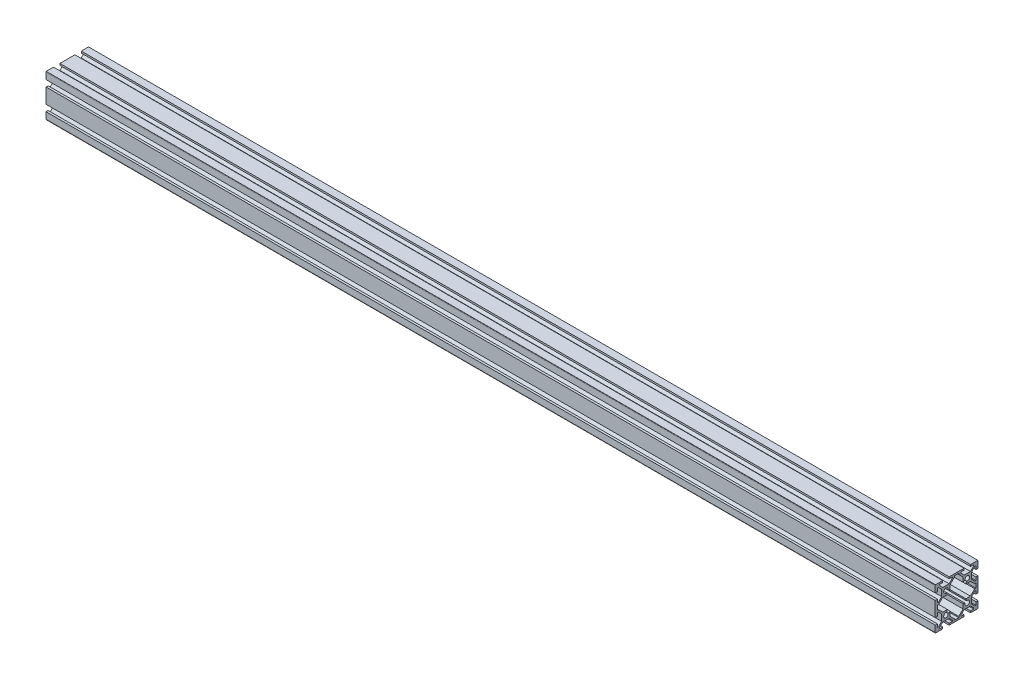
from build123d import *

# Parameters (mm, degrees)
BOSS_EXTRUDE1_DEPTH = 832


with BuildPart() as part:
    # Sketch1 → Boss-Extrude1 (new body)
    with BuildSketch(Plane(origin=(0, 0, 0), x_dir=(0, 0, -1), z_dir=(1, 0, 0))):
        with BuildLine():
            Line((-20, 19), (-20, 13))
            Line((-20, 13), (-18, 13))
            Line((-18, 13), (-18, 16))
            Line((-18, 16), (-17.060660172, 16))
            Line((-17.060660172, 16), (-14, 12.939339828))
            Line((-14, 12.939339828), (-14, 7.060660172))
            Line((-14, 7.060660172), (-17.060660172, 4))
            Line((-17.060660172, 4), (-18, 4))
            Line((-18, 4), (-18, 7))
            Line((-18, 7), (-20, 7))
            Line((-20, 7), (-20, -7))
            Line((-20, -7), (-18, -7))
            Line((-18, -7), (-18, -4))
            Line((-18, -4), (-17.060660172, -4))
            Line((-17.060660172, -4), (-14, -7.060660172))
            Line((-14, -7.060660172), (-14, -12.939339828))
            Line((-14, -12.939339828), (-17.060660172, -16))
            Line((-17.060660172, -16), (-18, -16))
            Line((-18, -16), (-18, -13))
            Line((-18, -13), (-20, -13))
            Line((-20, -13), (-20, -19))
            ThreePointArc((-20, -19), (-19.948683298, -19.316227766), (-19.8, -19.6))
            Line((-19.8, -19.6), (-13, -19.6))
            Line((-13, -19.6), (-13, -18))
            Line((-13, -18), (-16, -18))
            Line((-16, -18), (-16, -17.060660172))
            Line((-16, -17.060660172), (-12.939339828, -14))
            Line((-12.939339828, -14), (-7.060660172, -14))
            Line((-7.060660172, -14), (-4, -17.060660172))
            Line((-4, -17.060660172), (-4, -18))
            Line((-4, -18), (-7, -18))
            Line((-7, -18), (-7, -19.6))
            Line((-7, -19.6), (7, -19.6))
            Line((7, -19.6), (7, -18))
            Line((7, -18), (4, -18))
            Line((4, -18), (4, -17.060660172))
            Line((4, -17.060660172), (7.060660172, -14))
            Line((7.060660172, -14), (12.939339828, -14))
            Line((12.939339828, -14), (16, -17.060660172))
            Line((16, -17.060660172), (16, -18))
            Line((16, -18), (13, -18))
            Line((13, -18), (13, -19.6))
            Line((13, -19.6), (19.8, -19.6))
            ThreePointArc((19.8, -19.6), (19.948683298, -19.316227766), (20, -19))
            Line((20, -19), (20, -13))
            Line((20, -13), (18, -13))
            Line((18, -13), (18, -16))
            Line((18, -16), (17.060660172, -16))
            Line((17.060660172, -16), (14, -12.939339828))
            Line((14, -12.939339828), (14, -7.060660172))
            Line((14, -7.060660172), (17.060660172, -4))
            Line((17.060660172, -4), (18, -4))
            Line((18, -4), (18, -7))
            Line((18, -7), (20, -7))
            Line((20, -7), (20, 7))
            Line((20, 7), (18, 7))
            Line((18, 7), (18, 4))
            Line((18, 4), (17.060660172, 4))
            Line((17.060660172, 4), (14, 7.060660172))
            Line((14, 7.060660172), (14, 12.939339828))
            Line((14, 12.939339828), (17.060660172, 16))
            Line((17.060660172, 16), (18, 16))
            Line((18, 16), (18, 13))
            Line((18, 13), (20, 13))
            Line((20, 13), (20, 19))
            ThreePointArc((20, 19), (19.948683298, 19.316227766), (19.8, 19.6))
            Line((19.8, 19.6), (13, 19.6))
            Line((13, 19.6), (13, 18))
            Line((13, 18), (16, 18))
            Line((16, 18), (16, 17.060660172))
            Line((16, 17.060660172), (12.939339828, 14))
            Line((12.939339828, 14), (7.060660172, 14))
            Line((7.060660172, 14), (4, 17.060660172))
            Line((4, 17.060660172), (4, 18))
            Line((4, 18), (7, 18))
            Line((7, 18), (7, 19.6))
            Line((7, 19.6), (-7, 19.6))
            Line((-7, 19.6), (-7, 18))
            Line((-7, 18), (-4, 18))
            Line((-4, 18), (-4, 17.060660172))
            Line((-4, 17.060660172), (-7.060660172, 14))
            Line((-7.060660172, 14), (-12.939339828, 14))
            Line((-12.939339828, 14), (-16, 17.060660172))
            Line((-16, 17.060660172), (-16, 18))
            Line((-16, 18), (-13, 18))
            Line((-13, 18), (-13, 19.6))
            Line((-13, 19.6), (-19.8, 19.6))
            ThreePointArc((-19.8, 19.6), (-19.948683298, 19.316227766), (-20, 19))
        make_face()
        with BuildLine():
            Line((-16.939339828, 2), (-18, 2))
            Line((-18, 2), (-18, -2))
            Line((-18, -2), (-16.939339828, -2))
            Line((-16.939339828, -2), (-12.939339828, -6))
            Line((-12.939339828, -6), (-8.666662697, -6))
            Line((-8.666662697, -6), (-9.335919912, -8.007765667))
            ThreePointArc((-9.335919912, -8.007765667), (-11.48492424, -11.48492424), (-8.007765667, -9.335919912))
            Line((-8.007765667, -9.335919912), (-6, -8.666662697))
            Line((-6, -8.666662697), (-6, -12.939339828))
            Line((-6, -12.939339828), (-2, -16.939339828))
            Line((-2, -16.939339828), (-2, -18))
            Line((-2, -18), (2, -18))
            Line((2, -18), (2, -16.939339828))
            Line((2, -16.939339828), (6, -12.939339828))
            Line((6, -12.939339828), (6, -8.666662697))
            Line((6, -8.666662697), (8.007765667, -9.335919912))
            ThreePointArc((8.007765667, -9.335919912), (11.48492424, -11.48492424), (9.335919912, -8.007765667))
            Line((9.335919912, -8.007765667), (8.666662697, -6))
            Line((8.666662697, -6), (12.939339828, -6))
            Line((12.939339828, -6), (16.939339828, -2))
            Line((16.939339828, -2), (18, -2))
            Line((18, -2), (18, 2))
            Line((18, 2), (16.939339828, 2))
            Line((16.939339828, 2), (12.939339828, 6))
            Line((12.939339828, 6), (8.666662697, 6))
            Line((8.666662697, 6), (9.335919912, 8.007765667))
            ThreePointArc((9.335919912, 8.007765667), (11.48492424, 11.48492424), (8.007765667, 9.335919912))
            Line((8.007765667, 9.335919912), (6, 8.666662697))
            Line((6, 8.666662697), (6, 12.939339828))
            Line((6, 12.939339828), (2, 16.939339828))
            Line((2, 16.939339828), (2, 18))
            Line((2, 18), (-2, 18))
            Line((-2, 18), (-2, 16.939339828))
            Line((-2, 16.939339828), (-6, 12.939339828))
            Line((-6, 12.939339828), (-6, 8.666662697))
            Line((-6, 8.666662697), (-8.007765667, 9.335919912))
            ThreePointArc((-8.007765667, 9.335919912), (-11.48492424, 11.48492424), (-9.335919912, 8.007765667))
            Line((-9.335919912, 8.007765667), (-8.666662697, 6))
            Line((-8.666662697, 6), (-12.939339828, 6))
            Line((-12.939339828, 6), (-16.939339828, 2))
        make_face(mode=Mode.SUBTRACT)
    extrude(amount=BOSS_EXTRUDE1_DEPTH)


solid = part.part
